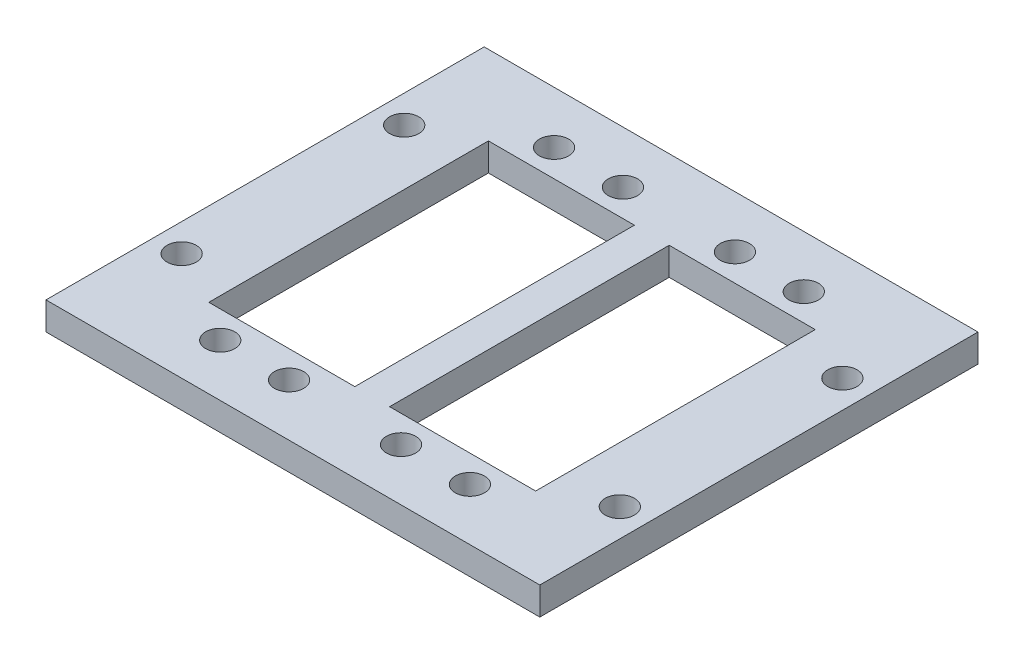
from build123d import *

# Parameters (mm, degrees)
SKETCH1_W           = 71
SKETCH1_H           = 63
SKETCH1_R           = 2.1
SKETCH1_W_2         = 20.991665644
SKETCH1_H_2         = 40.2
SKETCH1_W_3         = 21
BOSS_EXTRUDE1_DEPTH = 4


with BuildPart() as part:
    # Sketch1 → Boss-Extrude1 (new body)
    with BuildSketch(Plane(origin=(0, 0, 0), x_dir=(1, 0, 0), z_dir=(0, 1, 0))):
        with Locations((-62.085116344, -11.139897002)):
            Rectangle(SKETCH1_W, SKETCH1_H)
        with Locations((-80.035116344, 12.860102998)):
            Circle(SKETCH1_R, mode=Mode.SUBTRACT)
        with Locations((-70.135116344, 12.860102998)):
            Circle(SKETCH1_R, mode=Mode.SUBTRACT)
        with Locations((-54.035116344, 12.860102998)):
            Circle(SKETCH1_R, mode=Mode.SUBTRACT)
        with Locations((-44.135116344, 12.860102998)):
            Circle(SKETCH1_R, mode=Mode.SUBTRACT)
        with Locations((-30.585116344, 4.860102998)):
            Circle(SKETCH1_R, mode=Mode.SUBTRACT)
        with Locations((-93.585116344, 4.860102998)):
            Circle(SKETCH1_R, mode=Mode.SUBTRACT)
        with Locations((-30.585116344, -27.139897002)):
            Circle(SKETCH1_R, mode=Mode.SUBTRACT)
        with Locations((-44.135116344, -35.139897002)):
            Circle(SKETCH1_R, mode=Mode.SUBTRACT)
        with Locations((-54.035116344, -35.139897002)):
            Circle(SKETCH1_R, mode=Mode.SUBTRACT)
        with Locations((-80.035116344, -35.139897002)):
            Circle(SKETCH1_R, mode=Mode.SUBTRACT)
        with Locations((-70.135116344, -35.139897002)):
            Circle(SKETCH1_R, mode=Mode.SUBTRACT)
        with Locations((-93.585116344, -27.139897002)):
            Circle(SKETCH1_R, mode=Mode.SUBTRACT)
        with Locations((-75.080949166, -11.139897002)):
            Rectangle(SKETCH1_W_2, SKETCH1_H_2, mode=Mode.SUBTRACT)
        with Locations((-49.085116344, -11.139897002)):
            Rectangle(SKETCH1_W_3, SKETCH1_H_2, mode=Mode.SUBTRACT)
    extrude(amount=BOSS_EXTRUDE1_DEPTH)


solid = part.part
